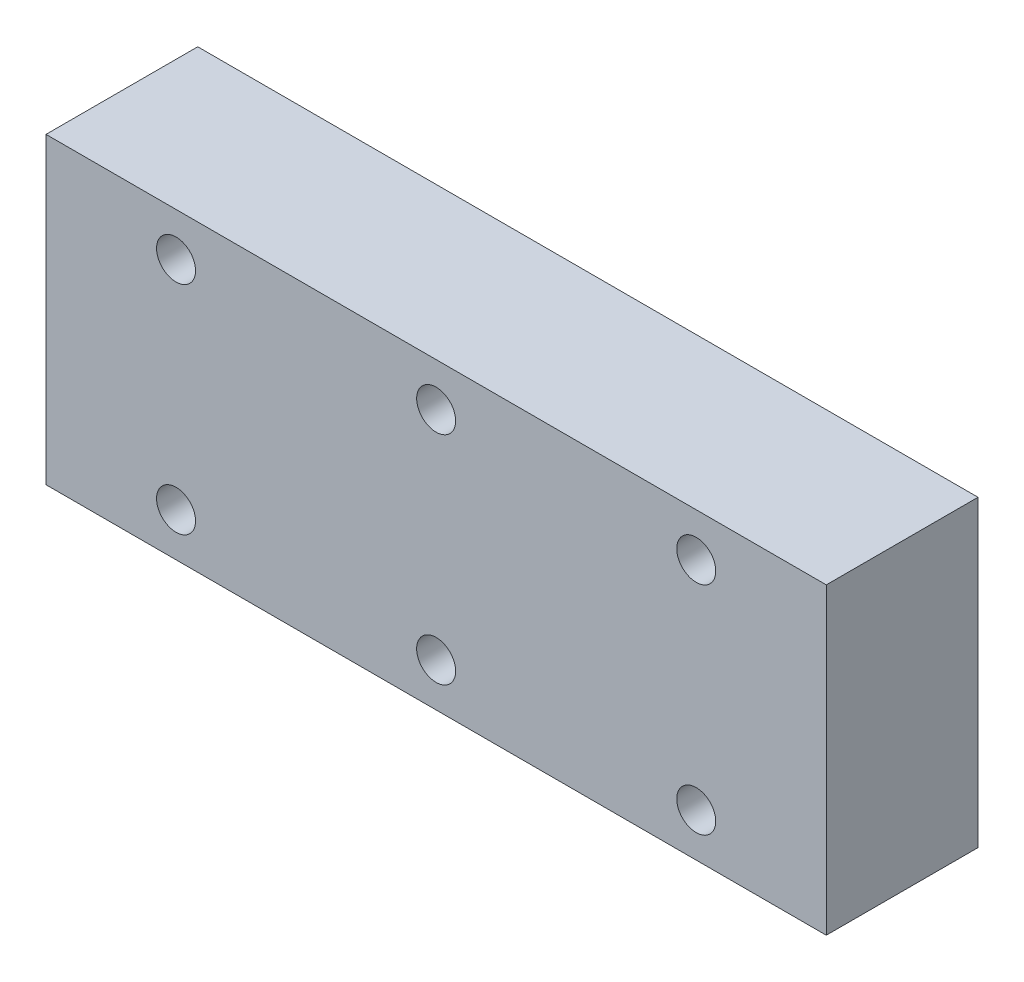
from build123d import *

# Parameters (mm, degrees)
CROQUIS1_W              = 18
CROQUIS1_H              = 7
SALIENTE_EXTRUIR1_DEPTH = 3.5
CROQUIS2_R              = 0.45
CORTAR_EXTRUIR1_DEPTH   = 5.75


with BuildPart() as part:
    # Croquis1 → Saliente-Extruir1 (new body)
    with BuildSketch(Plane.XY):
        Rectangle(CROQUIS1_W, CROQUIS1_H)
    extrude(amount=SALIENTE_EXTRUIR1_DEPTH)

    # Croquis2 → Cortar-Extruir1 (cut)
    with BuildSketch(Plane.XY.offset(3.5)):
        with Locations((-6, 2.5)):
            Circle(CROQUIS2_R)
        with Locations((-6, -2.5)):
            Circle(CROQUIS2_R)
        with Locations((6, 2.5)):
            Circle(CROQUIS2_R)
        with Locations((6, -2.5)):
            Circle(CROQUIS2_R)
        with Locations((0, 2.5)):
            Circle(CROQUIS2_R)
        with Locations((0, -2.5)):
            Circle(CROQUIS2_R)
    extrude(amount=-CORTAR_EXTRUIR1_DEPTH, mode=Mode.SUBTRACT)


solid = part.part
